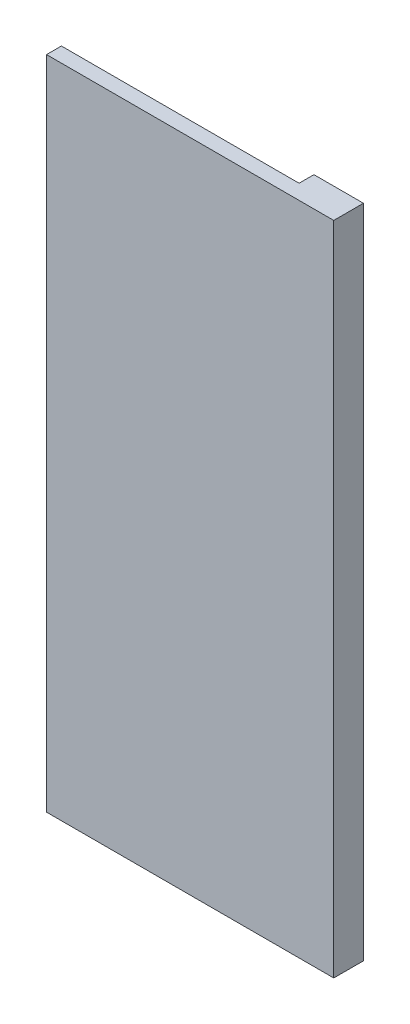
from build123d import *

# Parameters (mm, degrees)
BOSS_EXTRUDE1_DEPTH = 6
SKETCH2_W           = 116
SKETCH2_H           = 265
BOSS_EXTRUDE2_DEPTH = 6
SKETCH3_R           = 10
CUT_EXTRUDE1_DEPTH  = 6


with BuildPart() as part:
    # Sketch1 → Boss-Extrude1 (new body)
    with BuildSketch(Plane.XY):
        Polygon((68, 245), (48, 245), (48, 0), (-48, 0), (-48, -20), (68, -20), align=None)
    extrude(amount=-BOSS_EXTRUDE1_DEPTH)

    # Sketch2 → Boss-Extrude2 (add)
    with BuildSketch(Plane.XY):
        with Locations((10, 112.5)):
            Rectangle(SKETCH2_W, SKETCH2_H)
    extrude(amount=BOSS_EXTRUDE2_DEPTH)

    # Sketch3 → Cut-Extrude1 (cut)
    with BuildSketch(Plane(origin=(0, 0, -6), x_dir=(-1, 0, 0), z_dir=(0, 0, -1))):
        with Locations((-48, 0)):
            Circle(SKETCH3_R)
    extrude(amount=-CUT_EXTRUDE1_DEPTH, mode=Mode.SUBTRACT)


solid = part.part
